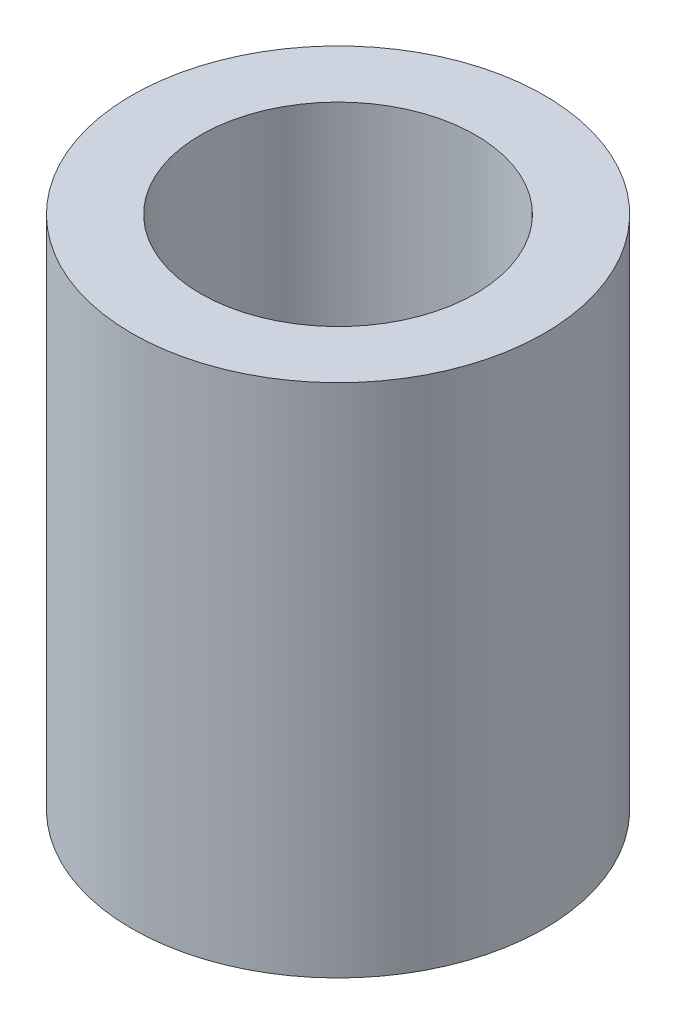
from build123d import *

# Parameters (mm, degrees)
SKETCH1_R           = 6
BOSS_EXTRUDE1_DEPTH = 15
SKETCH2_R           = 3
CUT_EXTRUDE1_DEPTH  = 7
SKETCH3_R           = 4
CUT_EXTRUDE2_DEPTH  = 7


with BuildPart() as part:
    # Sketch1 → Boss-Extrude1 (new body)
    with BuildSketch(Plane(origin=(0, 0, 0), x_dir=(1, 0, 0), z_dir=(0, 1, 0))):
        Circle(SKETCH1_R)
    extrude(amount=BOSS_EXTRUDE1_DEPTH)

    # Sketch2 → Cut-Extrude1 (cut)
    with BuildSketch(Plane.XZ):
        Circle(SKETCH2_R)
    extrude(amount=-CUT_EXTRUDE1_DEPTH, mode=Mode.SUBTRACT)

    # Sketch3 → Cut-Extrude2 (cut)
    with BuildSketch(Plane(origin=(0, 15, 0), x_dir=(1, 0, 0), z_dir=(0, 1, 0))):
        Circle(SKETCH3_R)
    extrude(amount=-CUT_EXTRUDE2_DEPTH, mode=Mode.SUBTRACT)


solid = part.part
